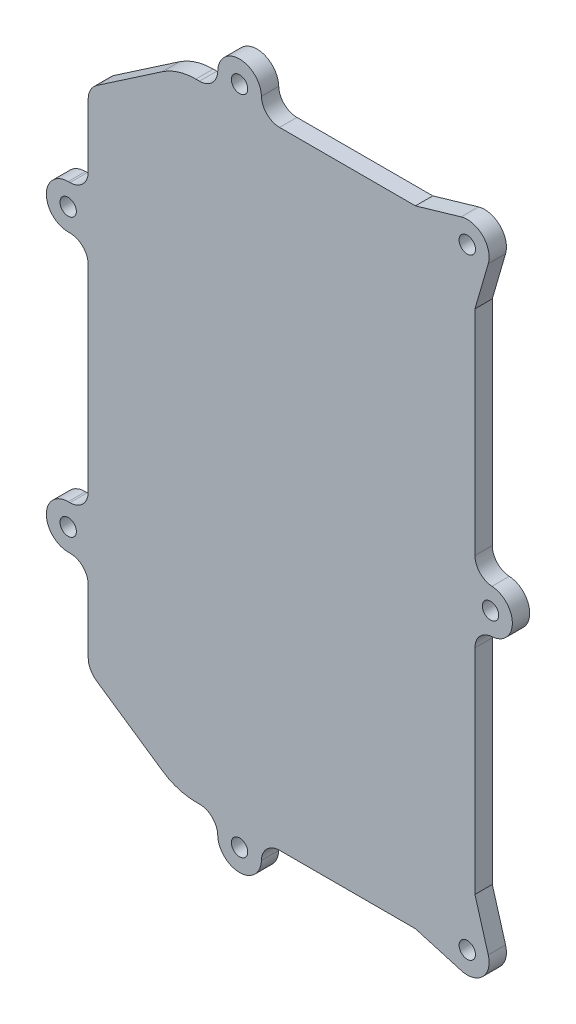
from build123d import *

# Parameters (mm, degrees)
BOSS_EXTRUDE1_DEPTH  = 4.7625
M4_CLEARANCE_HOLE1_D = 4.5


with BuildPart() as part:
    # Sketch1 → Boss-Extrude1 (new body)
    with BuildSketch(Plane.XY):
        with BuildLine():
            Line((-97.832602581, 37.475432296), (-97.832602581, 20.113840969))
            ThreePointArc((-97.832602581, 20.113840969), (-97.214499379, 17.621477955), (-95.503441204, 15.706744322))
            Line((-95.503441204, 15.706744322), (-77.448765904, 3.396738436))
            ThreePointArc((-77.448765904, 3.396738436), (-73.061911597, 1.284058495), (-68.247222211, 0.558335853))
            Line((-68.247222211, 0.558335853), (-67.24507567, 0.558335853))
            ThreePointArc((-67.24507567, 0.558335853), (-63.744637386, -0.87137959), (-62.24605137, -4.342891419))
            ThreePointArc((-62.24605137, -4.342891419), (-56.247222211, -10.224364147), (-50.248393051, -4.342891419))
            ThreePointArc((-50.248393051, -4.342891419), (-48.749807036, -0.87137959), (-45.249368751, 0.558335853))
            Line((-45.249368751, 0.558335853), (-7.916602581, 0.558335853))
            Line((-7.916602581, 0.558335853), (4.631523913, -3.09333052))
            ThreePointArc((4.631523913, -3.09333052), (10.550693091, -1.574959819), (12.069063792, 4.344209359))
            Line((12.069063792, 4.344209359), (8.417397419, 16.892335853))
            Line((8.417397419, 16.892335853), (8.417397419, 75.581748009))
            ThreePointArc((8.417397419, 75.581748009), (9.768409389, 79.000064314), (13.091351964, 80.57110612))
            ThreePointArc((13.091351964, 80.57110612), (18.700097419, 86.558335853), (13.091351964, 92.545565587))
            ThreePointArc((13.091351964, 92.545565587), (9.768409389, 94.116607393), (8.417397419, 97.534923698))
            Line((8.417397419, 97.534923698), (8.417397419, 156.224335853))
            Line((8.417397419, 156.224335853), (12.069063792, 168.772462348))
            ThreePointArc((12.069063792, 168.772462348), (10.550693091, 174.691631526), (4.631523913, 176.210002227))
            Line((4.631523913, 176.210002227), (-7.916602581, 172.558335853))
            Line((-7.916602581, 172.558335853), (-45.249368751, 172.558335853))
            ThreePointArc((-45.249368751, 172.558335853), (-48.749807036, 173.988051296), (-50.248393051, 177.459563126))
            ThreePointArc((-50.248393051, 177.459563126), (-56.247222211, 183.341035853), (-62.24605137, 177.459563126))
            ThreePointArc((-62.24605137, 177.459563126), (-63.744637386, 173.988051296), (-67.24507567, 172.558335853))
            Line((-67.24507567, 172.558335853), (-68.247222211, 172.558335853))
            ThreePointArc((-68.247222211, 172.558335853), (-73.061911597, 171.832613212), (-77.448765904, 169.719933271))
            Line((-77.448765904, 169.719933271), (-95.503441204, 157.409927385))
            ThreePointArc((-95.503441204, 157.409927385), (-97.214499379, 155.495193752), (-97.832602581, 153.002830738))
            Line((-97.832602581, 153.002830738), (-97.832602581, 135.641239411))
            ThreePointArc((-97.832602581, 135.641239411), (-99.297068676, 132.105705505), (-102.832602581, 130.641239411))
            Line((-102.832602581, 130.641239411), (-103.332602581, 130.641239411))
            ThreePointArc((-103.332602581, 130.641239411), (-109.332602581, 124.641239411), (-103.332602581, 118.641239411))
            Line((-103.332602581, 118.641239411), (-102.832602581, 118.641239411))
            ThreePointArc((-102.832602581, 118.641239411), (-99.297068676, 117.176773317), (-97.832602581, 113.641239411))
            Line((-97.832602581, 113.641239411), (-97.832602581, 59.475432296))
            ThreePointArc((-97.832602581, 59.475432296), (-99.297068676, 55.93989839), (-102.832602581, 54.475432296))
            Line((-102.832602581, 54.475432296), (-103.332602581, 54.475432296))
            ThreePointArc((-103.332602581, 54.475432296), (-109.332602581, 48.475432296), (-103.332602581, 42.475432296))
            Line((-103.332602581, 42.475432296), (-102.832602581, 42.475432296))
            ThreePointArc((-102.832602581, 42.475432296), (-99.297068676, 41.010966202), (-97.832602581, 37.475432296))
        make_face()
    extrude(amount=-BOSS_EXTRUDE1_DEPTH)

    # M4 Clearance Hole1 (through all)
    with Locations(Plane(origin=(0, 0, -4.7625), x_dir=(-1, 0, 0), z_dir=(0, 0, -1))):
        with Locations((103.332602581, 48.475432296), (56.247222211, -4.224364147), (-12.700097419, 86.558335853), (56.247222211, 177.341035853), (103.332602581, 124.641239411), (-6.308052404, 2.667680868), (-6.308052404, 170.448990839)):
            Hole(M4_CLEARANCE_HOLE1_D / 2)


solid = part.part
